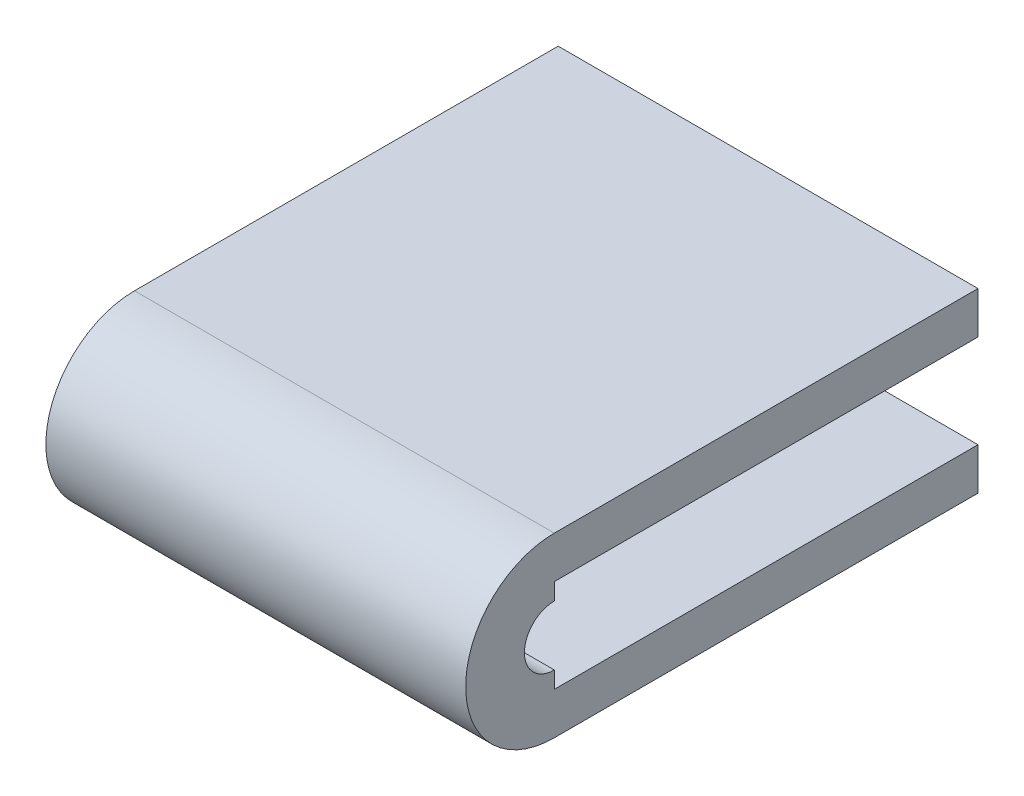
from build123d import *

# Parameters (mm, degrees)
SKETCH1_W           = 28.8417
SKETCH1_H           = 2.8575
BOSS_EXTRUDE1_DEPTH = 28.575


with BuildPart() as part:
    # Sketch1 → Boss-Extrude1 (new body)
    with BuildSketch(Plane(origin=(0, 0, 0), x_dir=(0, 0, -1), z_dir=(1, 0, 0))):
        with Locations((14.42085, 4.60375)):
            Rectangle(SKETCH1_W, SKETCH1_H)
        with BuildLine():
            ThreePointArc((0, 2.032), (-2.032, 0), (0, -2.032))
            Line((0, -2.032), (0, -6.0325))
            ThreePointArc((0, -6.0325), (-6.0325, 0), (0, 6.0325))
            Line((0, 6.0325), (0, 2.032))
        make_face()
        with Locations((14.42085, -4.60375)):
            Rectangle(SKETCH1_W, SKETCH1_H)
    extrude(amount=BOSS_EXTRUDE1_DEPTH)


solid = part.part
